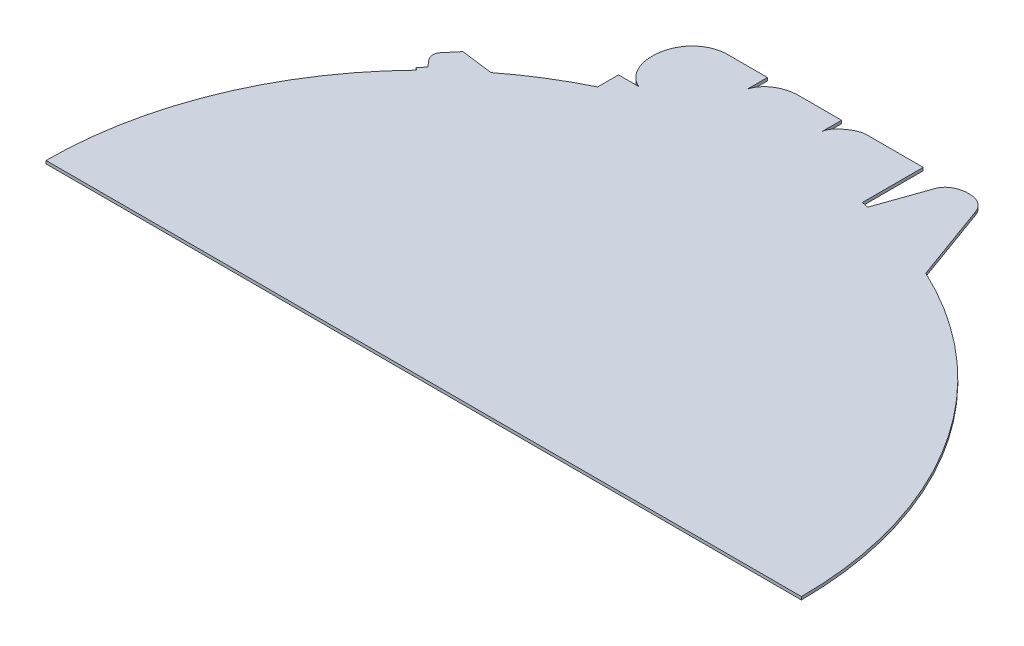
from build123d import *

# Parameters (mm, degrees)
AUFSATZ_LINEAR_AUSTRAGEN1_DEPTH = 2


with BuildPart() as part:
    # Skizze1 → Aufsatz-Linear austragen1 (new body)
    with BuildSketch(Plane(origin=(0, 0, 0), x_dir=(1, 0, 0), z_dir=(0, 1, 0))):
        with BuildLine():
            Line((-111.014713036, 96.629952772), (-111.014713036, 82.637944818))
            ThreePointArc((-111.014713036, 82.637944818), (-133.773093964, 70.056299779), (-155.121581381, 55.20760356))
            Line((-155.121581381, 55.20760356), (-176.68443544, 58.018627787))
            Line((-176.68443544, 58.018627787), (-184.391490567, 48.817347687))
            ThreePointArc((-184.391490567, 48.817347687), (-184.856553748, 45.106419523), (-183.300343728, 41.705613446))
            Line((-183.300343728, 41.705613446), (-179.406379638, 37.139090384))
            Line((-179.406379638, 37.139090384), (-183.244712688, 33.192915196))
            Line((-183.244712688, 33.192915196), (-181.577621487, 31.571382711))
            ThreePointArc((-181.577621487, 31.571382711), (-234.688503419, -49.730678526), (-253.304201651, -145.041993281))
            Line((-253.304201651, -145.041993281), (253.3, -145.041993281))
            ThreePointArc((253.3, -145.041993281), (213.679953091, -9.020178425), (107.2140887, 84.450148167))
            Line((107.2140887, 84.450148167), (88.10582283, 137.079482634))
            ThreePointArc((88.10582283, 137.079482634), (83.551519794, 142.896881485), (76.497849408, 145.094502845))
            Line((76.497849408, 145.094502845), (73.732714296, 145.093801448))
            add(Edge.make_bspline(
                [(61.241798353, 137.079482633), (63.12872124, 142.063691586), (68.556952847, 144.691016446), (73.732714296, 145.093801449)],
                knots=[0, 0, 0, 0, 0.846643391, 0.846643391, 0.846643391, 0.846643391], degree=3))
            Line((61.241798353, 137.079482633), (49.403316926, 103.395240199))
            ThreePointArc((49.403316926, 103.395240199), (47.136635501, 103.835273299), (44.866037129, 104.254626189))
            Line((44.866037129, 104.254626189), (44.866037129, 145.086479208))
            Line((44.866037129, 145.086479208), (8.335497246, 145.077212974))
            Line((8.335497246, 145.077212974), (6.400480376, 145.076722143))
            add(Edge.make_bspline(
                [(-9.859797389, 131.748243103), (-9.468785698, 135.744179636), (-3.989815347, 141.108587237), (2.485358217, 144.80702629), (6.400480376, 145.076722143)],
                knots=[0, 0, 0, 0, 0.454488203, 0.924546926, 0.924546926, 0.924546926, 0.924546926], degree=3))
            Line((-9.859797389, 131.748243103), (-9.859797389, 145.072597607))
            Line((-9.859797389, 145.072597607), (-38.85877651, 145.065241807))
            add(Edge.make_bspline(
                [(-59.546942015, 131.748243103), (-56.872959995, 140.401818923), (-47.428583468, 145.063068014), (-38.85877651, 145.065241807)],
                knots=[0, 0, 0, 0, 1, 1, 1, 1], degree=3))
            Line((-59.546942015, 131.748243103), (-59.546942015, 145.059994105))
            Line((-59.546942015, 145.059994105), (-87.539763433, 145.052893525))
            add(Edge.make_bspline(
                [(-97.500864535, 96.629952772), (-104.579533848, 99.859372788), (-116.831393377, 118.836705983), (-105.084694212, 143.726198357), (-87.539763433, 145.052893525)],
                knots=[0, 0, 0, 0, 0.332503248, 1, 1, 1, 1], degree=3))
            Line((-97.500864535, 96.629952772), (-111.014713036, 96.629952772))
        make_face()
    extrude(amount=AUFSATZ_LINEAR_AUSTRAGEN1_DEPTH)


solid = part.part
